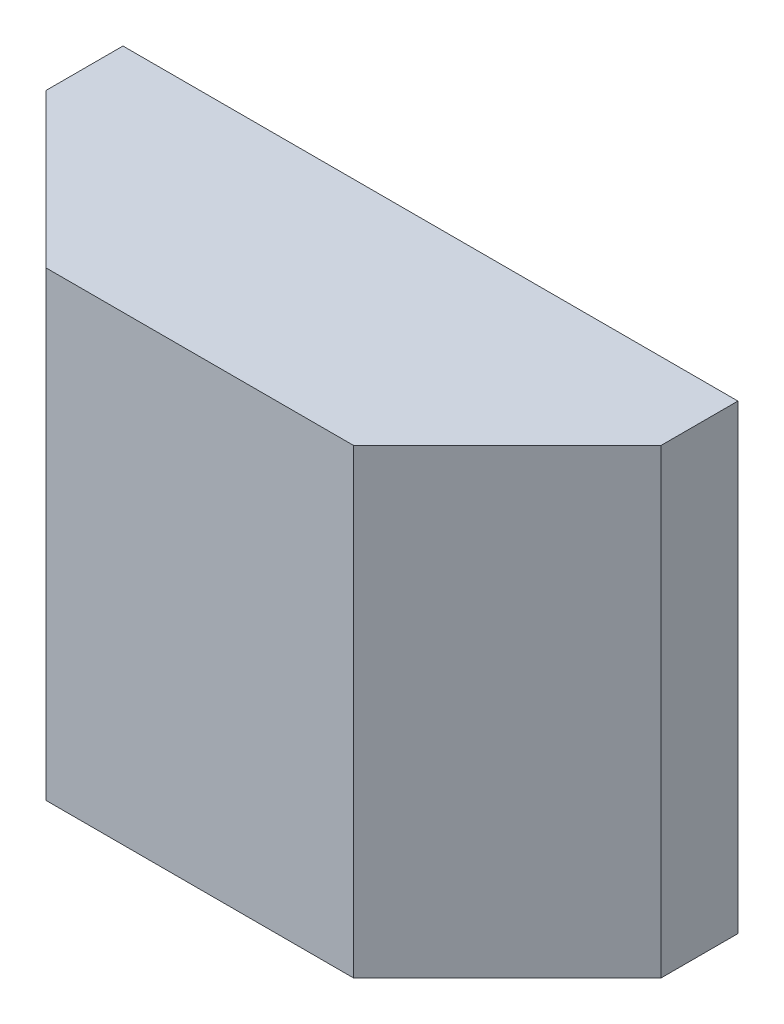
from build123d import *

# Parameters (mm, degrees)
SKETCH_1_W      = 4
SKETCH_1_H      = 3
EXTRUDE_1_DEPTH = 1.5
CHAMFER_1_SIZE  = 1


with BuildPart() as part:
    # Эскиз1 → Бобышка-Вытянуть1 (new body)
    with BuildSketch(Plane.XY):
        Rectangle(SKETCH_1_W, SKETCH_1_H)
    extrude(amount=EXTRUDE_1_DEPTH)

    # Фаска1
    chamfer_1_edges = [part.edges().sort_by_distance(p)[0] for p in [
        (-2, 0, 1.5),
        (2, 0, 1.5),
    ]]
    chamfer(chamfer_1_edges, length=CHAMFER_1_SIZE)


solid = part.part
